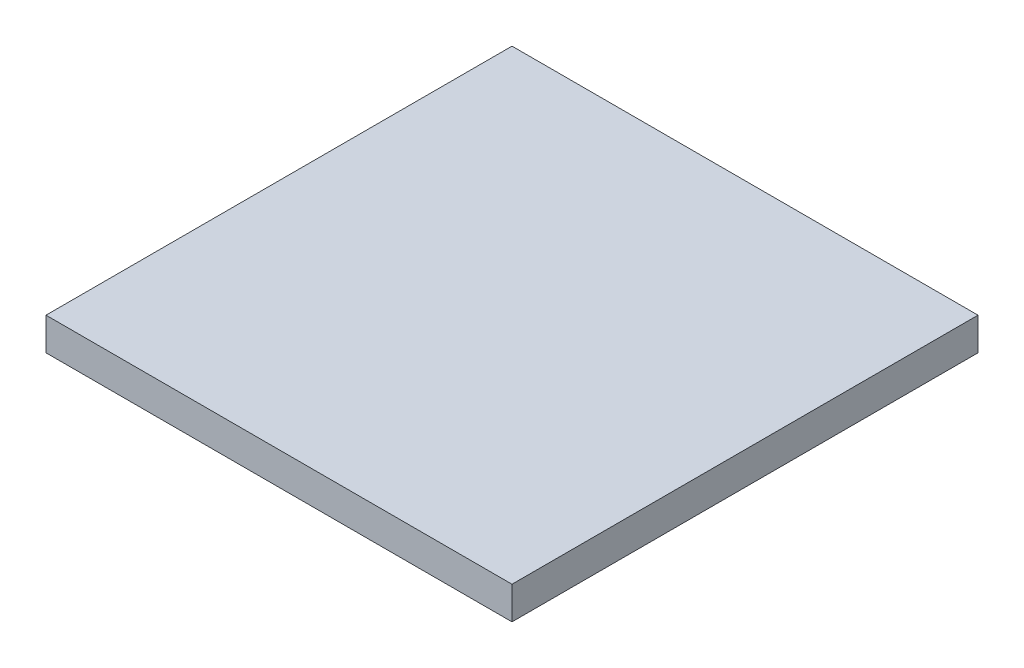
from build123d import *

# Parameters (mm, degrees)
SKETCH1_W           = 1000
SKETCH1_H           = 70
BOSS_EXTRUDE1_DEPTH = 1000


with BuildPart() as part:
    # Sketch1 → Boss-Extrude1 (new body)
    with BuildSketch(Plane(origin=(0, 0, 0), x_dir=(0, 0, -1), z_dir=(1, 0, 0))):
        with Locations((500, 35)):
            Rectangle(SKETCH1_W, SKETCH1_H)
    extrude(amount=BOSS_EXTRUDE1_DEPTH)


solid = part.part
